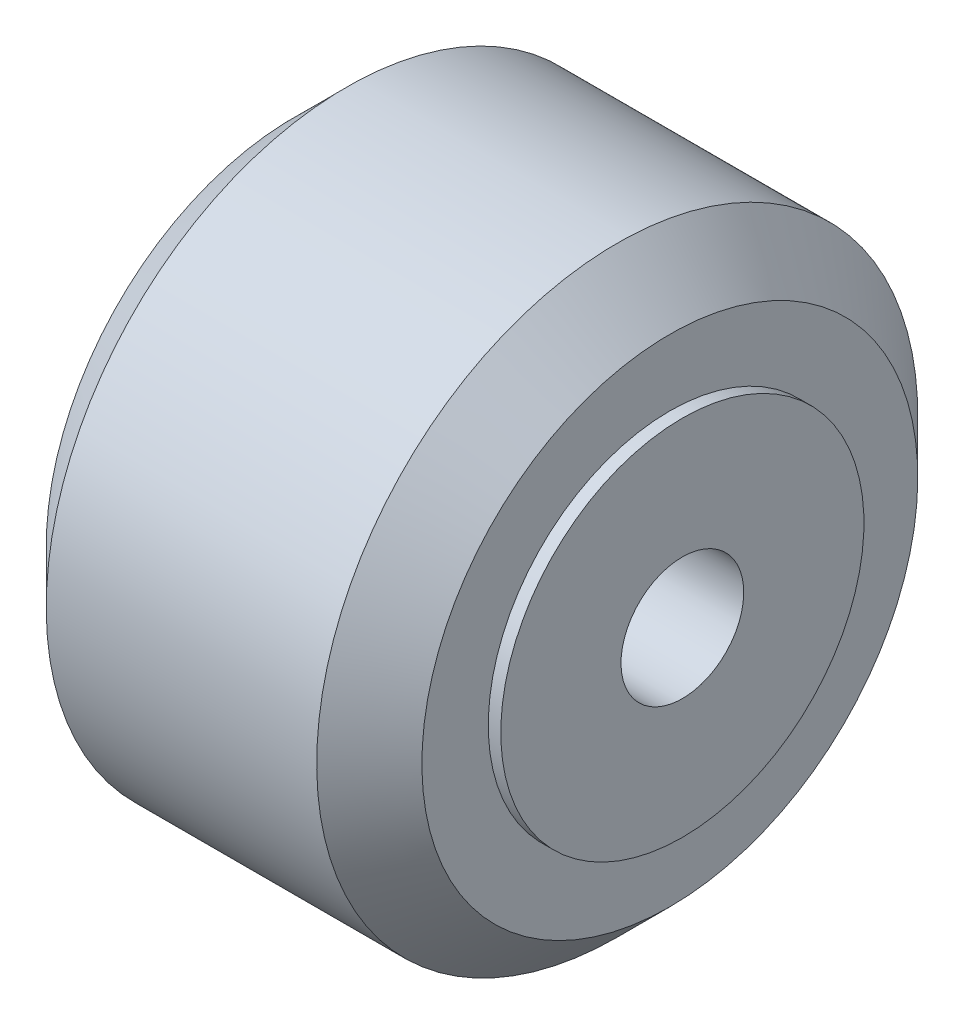
from build123d import *

# Parameters (mm, degrees)
CROQUIS2_R                   = 7.25
CROQUIS2_R_2                 = 2.45
SALIENTE_EXTRUIR1_DEPTH      = 0.5
SALIENTE_EXTRUIR1_DEPTH_BACK = 15.6
CROQUIS3_R                   = 7.25
CORTAR_EXTRUIR1_DEPTH        = 14
CORTAR_EXTRUIR1_DEPTH_BACK   = 17.5


with BuildPart() as part:
    # Croquis1 → Revolución1 (revolve)
    with BuildSketch(Plane.XY):
        Polygon((5.4, 12), (-5.4, 12), (-7.5, 9.9), (-7.5, 2.45), (-3, 2.45), (3, 2.45), (7.5, 2.45), (7.5, 9.9), align=None)
    revolve(axis=Axis((0, 0, 0), (1, 0, 0)))

    # Croquis3 → Cortar-Extruir1 (cut, two sides)
    with BuildSketch(Plane(origin=(7.5, 0, 0), x_dir=(0, 0, -1), z_dir=(1, 0, 0))) as cortar_extruir1_sk:
        Circle(CROQUIS3_R)
    extrude(amount=CORTAR_EXTRUIR1_DEPTH, mode=Mode.SUBTRACT)
    extrude(cortar_extruir1_sk.sketch, amount=-CORTAR_EXTRUIR1_DEPTH_BACK, mode=Mode.SUBTRACT)


with BuildPart() as body_2:
    # Croquis2 → Saliente-Extruir1 (new body, two sides)
    with BuildSketch(Plane(origin=(7.5, 0, 0), x_dir=(0, 0, -1), z_dir=(1, 0, 0))) as saliente_extruir1_sk:
        Circle(CROQUIS2_R)
        Circle(CROQUIS2_R_2, mode=Mode.SUBTRACT)
    extrude(amount=SALIENTE_EXTRUIR1_DEPTH)
    extrude(saliente_extruir1_sk.sketch, amount=-SALIENTE_EXTRUIR1_DEPTH_BACK)


solid = Compound([part.part, body_2.part])
